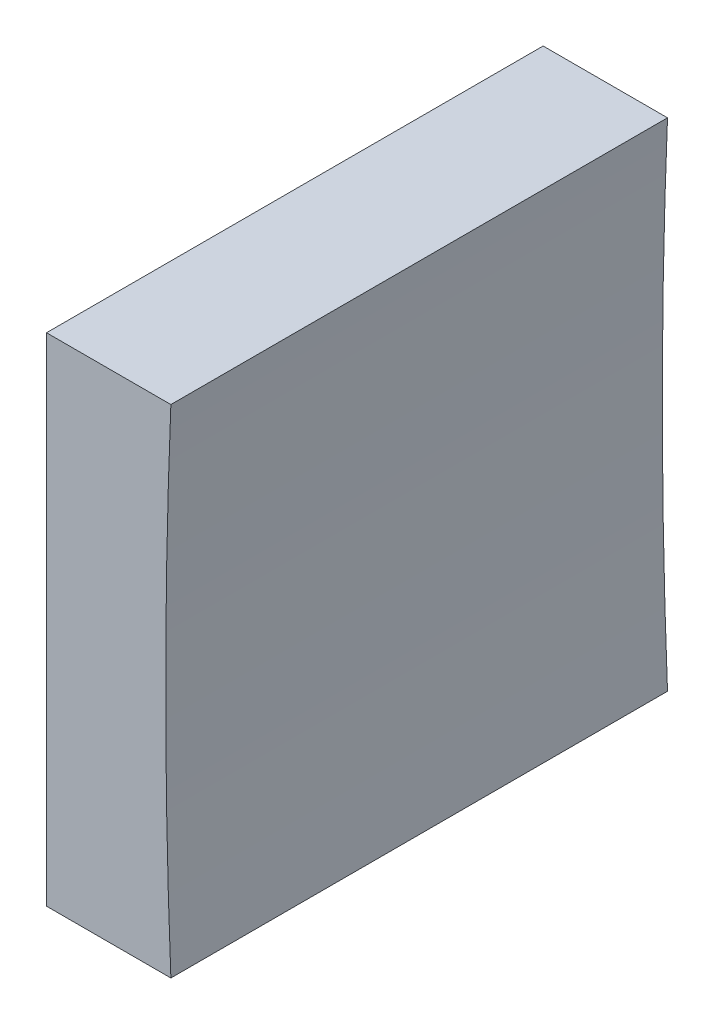
from build123d import *

# Parameters (mm, degrees)
EXTRUDE_1_DEPTH = 12.5


with BuildPart() as part:
    # 草图1 → 凸台-拉伸1 (new body)
    with BuildSketch(Plane.XY):
        with BuildLine():
            Line((142.353567816, 33.428964634), (142.353567816, 39.678964634))
            Line((142.353567816, 39.678964634), (145.483832712, 39.678964634))
            ThreePointArc((145.483832712, 39.678964634), (145.353567816, 33.428964634), (145.483832712, 27.178964634))
            Line((145.483832712, 27.178964634), (142.353567816, 27.178964634))
            Line((142.353567816, 27.178964634), (142.353567816, 33.428964634))
        make_face()
    extrude(amount=EXTRUDE_1_DEPTH)


solid = part.part
